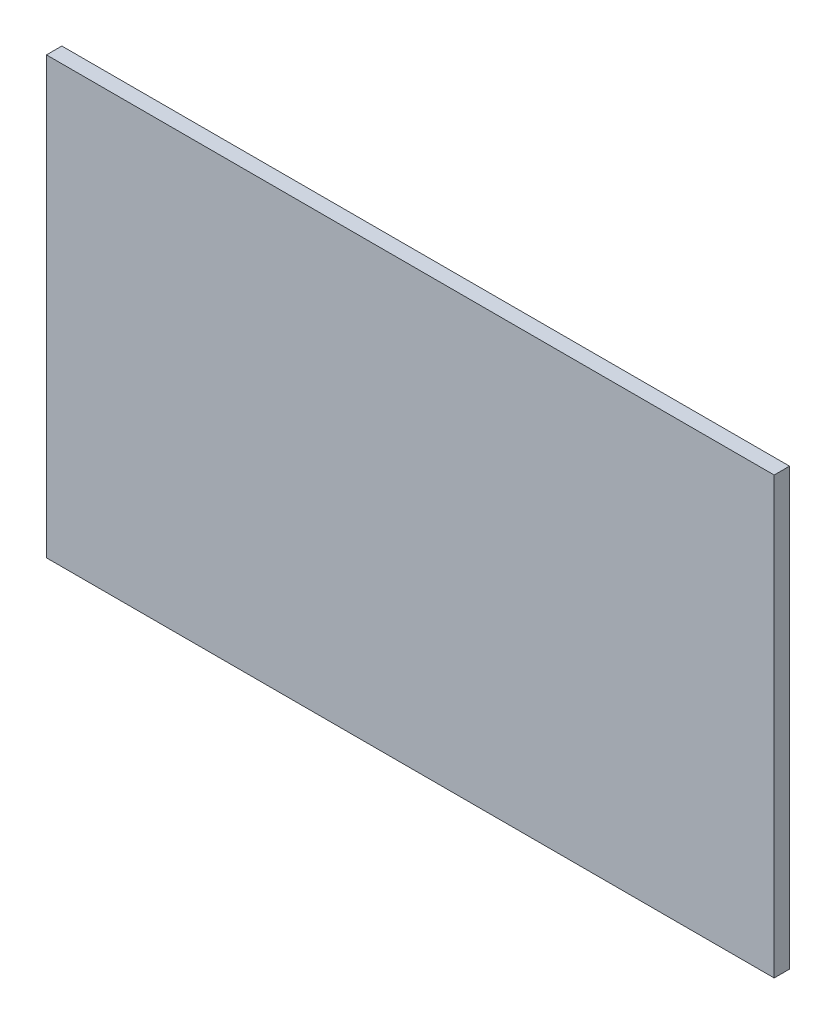
from build123d import *

# Parameters (mm, degrees)
ESBO_O1_W                = 150.35
ESBO_O1_H                = 90
RESSALTO_EXTRUS_O1_DEPTH = 3.175


with BuildPart() as part:
    # Esboço1 → Ressalto-extrusão1 (new body)
    with BuildSketch(Plane.XY):
        Rectangle(ESBO_O1_W, ESBO_O1_H)
    extrude(amount=RESSALTO_EXTRUS_O1_DEPTH)


solid = part.part
